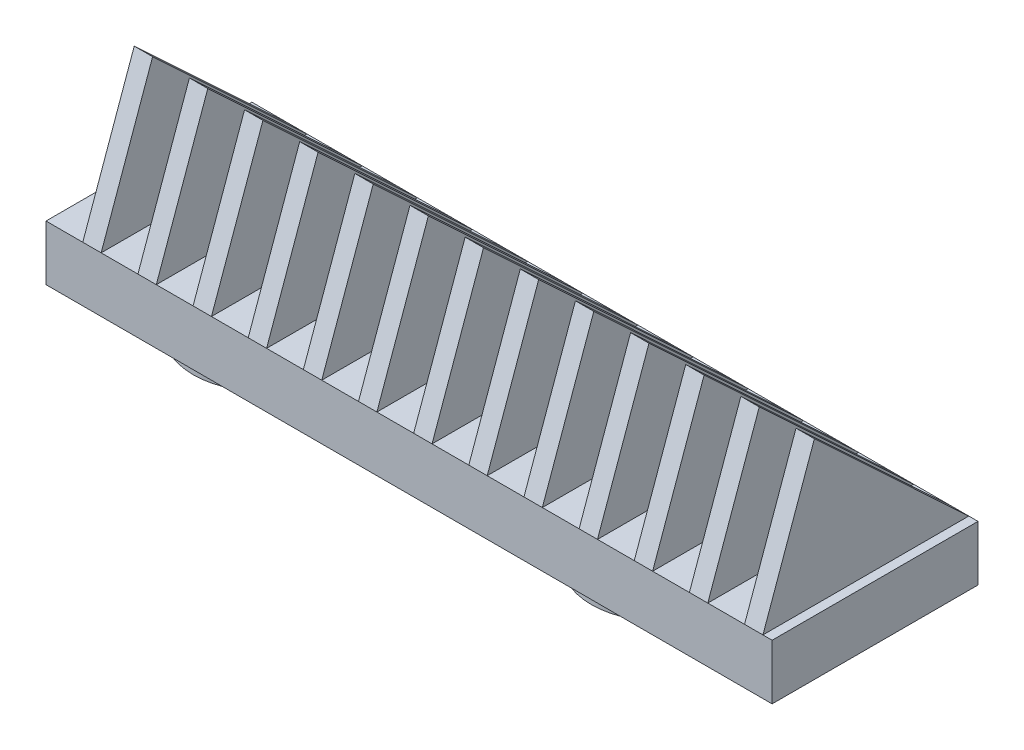
from build123d import *

# Parameters (mm, degrees)
SKETCH1_W           = 211.1375
SKETCH1_H           = 35.56
BOSS_EXTRUDE1_DEPTH = 9.525
SKETCH6_R           = 12.192
BOSS_EXTRUDE4_DEPTH = 6.35
BOSS_EXTRUDE5_DEPTH = 3.175
LPATTERN1_COUNT     = 22
LPATTERN1_PITCH     = 9.525
SKETCH10_W          = 45.550099835
SKETCH10_H          = 62.093170918
CUT_EXTRUDE1_DEPTH  = 85.725
SKETCH11_W          = 25.4
SKETCH11_H          = 7.62
CUT_EXTRUDE2_DEPTH  = 12.7


with BuildPart() as part:
    # Sketch1 → Boss-Extrude1 (new body)
    with BuildSketch(Plane(origin=(0, 0, 0), x_dir=(1, 0, 0), z_dir=(0, 1, 0))):
        with Locations((-105.56875, 17.78)):
            Rectangle(SKETCH1_W, SKETCH1_H)
    extrude(amount=BOSS_EXTRUDE1_DEPTH)

    # Sketch6 → Boss-Extrude4 (add)
    with BuildSketch(Plane(origin=(0, 0, 0), x_dir=(-1, 0, 0), z_dir=(0, -1, 0))):
        with Locations((105.56875, 17.78)):
            Circle(SKETCH6_R)
        with Locations((36.79825, 17.78)):
            Circle(SKETCH6_R)
        with Locations((174.33925, 17.78)):
            Circle(SKETCH6_R)
    extrude(amount=BOSS_EXTRUDE4_DEPTH)

    # Sketch9 → Boss-Extrude5 (add)
    with BuildSketch(Plane.ZY.offset(204.7875)):
        Polygon((-35.56, 9.525), (0, 9.525), (-8.89, 34.417), align=None)
    boss_extrude5 = extrude(amount=-BOSS_EXTRUDE5_DEPTH)

    # LPattern1: Boss-Extrude5 ×22
    with Locations(*[(i * LPATTERN1_PITCH, 0, 0) for i in range(1, LPATTERN1_COUNT)]):
        add(boss_extrude5)

    # Sketch10 → Cut-Extrude1 (cut)
    with BuildSketch(Plane.ZY.offset(211.1375)):
        with Locations((-16.930184705, 4.77052578)):
            Rectangle(SKETCH10_W, SKETCH10_H)
    extrude(amount=-CUT_EXTRUDE1_DEPTH, mode=Mode.SUBTRACT)

    # Sketch11 → Cut-Extrude2 (cut)
    with BuildSketch(Plane.ZY.offset(125.4125)):
        with Locations((-17.78, 4.7625)):
            Rectangle(SKETCH11_W, SKETCH11_H)
    extrude(amount=-CUT_EXTRUDE2_DEPTH, mode=Mode.SUBTRACT)


solid = part.part
